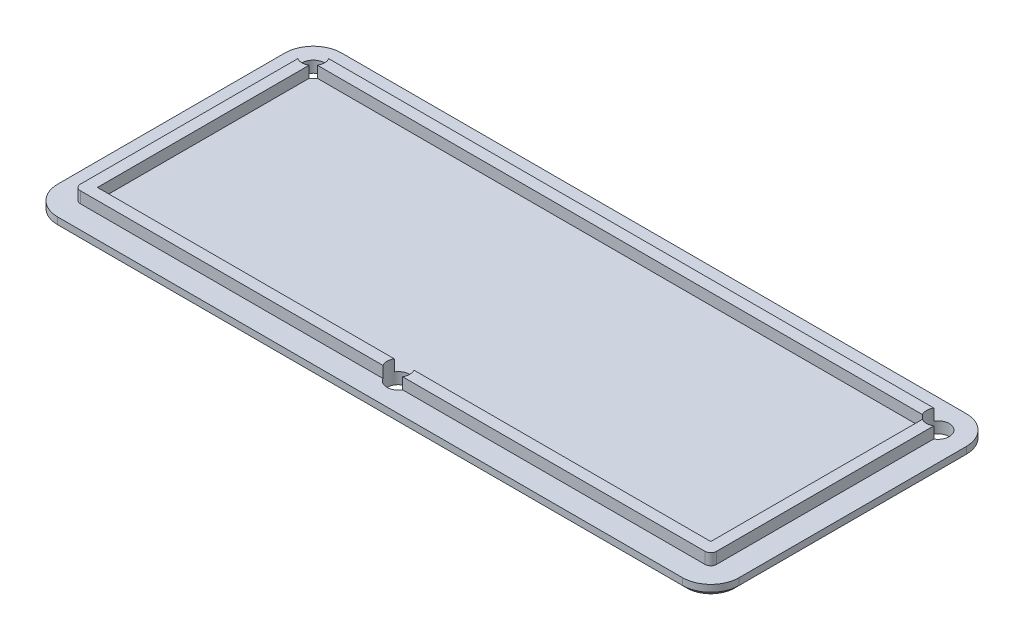
from build123d import *

# Parameters (mm, degrees)
SKETCH1_W           = 76.2
SKETCH1_H           = 31.75
BOSS_EXTRUDE1_DEPTH = 1.27
FILLET1_R           = 3.175
SKETCH2_W           = 68.58
SKETCH2_H           = 24.13
BOSS_EXTRUDE2_DEPTH = 1.27
SKETCH3_R           = 1.27
CUT_EXTRUDE1_DEPTH  = 42.353079994
CHAMFER1_SIZE       = 0.508


with BuildPart() as part:
    # Sketch1 → Boss-Extrude1 (new body)
    with BuildSketch(Plane(origin=(0, 0, 0), x_dir=(1, 0, 0), z_dir=(0, 1, 0))):
        Rectangle(SKETCH1_W, SKETCH1_H)
    extrude(amount=BOSS_EXTRUDE1_DEPTH)

    # Fillet1
    fillet1_edges = [part.edges().sort_by_distance(p)[0] for p in [
        (-38.1, 0.635, -15.875),
        (38.1, 0.635, -15.875),
        (38.1, 0.635, 15.875),
        (-38.1, 0.635, 15.875),
    ]]
    fillet(fillet1_edges, radius=FILLET1_R)

    # Sketch2 → Boss-Extrude2 (add)
    with BuildSketch(Plane(origin=(0, 1.27, 0), x_dir=(1, 0, 0), z_dir=(0, 1, 0))):
        with BuildLine():
            Line((34.925, 13.335), (-34.925, 13.335))
            ThreePointArc((-34.925, 13.335), (-35.374012806, 13.149012806), (-35.56, 12.7))
            Line((-35.56, 12.7), (-35.56, -12.7))
            ThreePointArc((-35.56, -12.7), (-35.374012806, -13.149012806), (-34.925, -13.335))
            Line((-34.925, -13.335), (34.925, -13.335))
            ThreePointArc((34.925, -13.335), (35.374012806, -13.149012806), (35.56, -12.7))
            Line((35.56, -12.7), (35.56, 12.7))
            ThreePointArc((35.56, 12.7), (35.374012806, 13.149012806), (34.925, 13.335))
        make_face()
        Rectangle(SKETCH2_W, SKETCH2_H, mode=Mode.SUBTRACT)
    extrude(amount=BOSS_EXTRUDE2_DEPTH)

    # Sketch3 → Cut-Extrude1 (cut, through all)
    with BuildSketch(Plane.XZ):
        with Locations(Location((34.925, -12.7, 0), (0, 0, 270))):
            Circle(SKETCH3_R)
        with Locations(Location((0, 12.7, 0), (0, 0, 270))):
            Circle(SKETCH3_R)
        with Locations(Location((-34.925, -12.7, 0), (0, 0, 270))):
            Circle(SKETCH3_R)
    extrude(amount=-CUT_EXTRUDE1_DEPTH, mode=Mode.SUBTRACT)

    # Chamfer1
    chamfer1_edges = [part.edges().sort_by_distance(p)[0] for p in [
        (-38.1, 0, 0),
        (0, 0, -15.875),
        (38.1, 0, 0),
        (0, 0, 15.875),
        (-37.17006403, 0, 14.94506403),
        (37.17006403, 0, 14.94506403),
        (37.17006403, 0, -14.94506403),
        (-37.17006403, 0, -14.94506403),
    ]]
    chamfer(chamfer1_edges, length=CHAMFER1_SIZE)


solid = part.part
